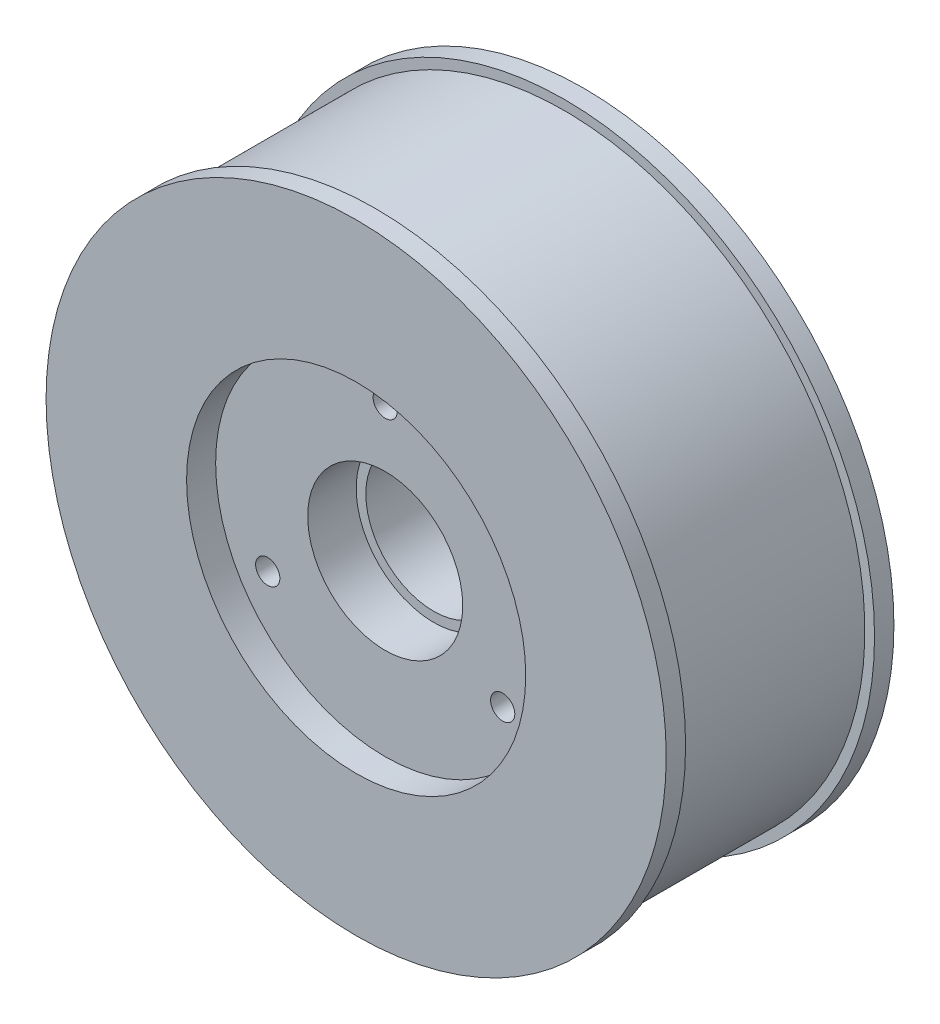
from build123d import *

# Parameters (mm, degrees)
SKETCH1_R             = 31
EXTRUDE1_DEPTH        = 19.5
SKETCH2_R             = 32
EXTRUDE2_DEPTH        = 2
SKETCH3_R             = 32
EXTRUDE3_DEPTH        = 2
SKETCH4_R             = 7
CUT_EXTRUDE1_DEPTH    = 24.5
SKETCH5_R             = 8
CUT_EXTRUDE2_DEPTH    = 9.5
SKETCH6_R             = 18
CUT_EXTRUDE3_DEPTH    = 5
M3X0_5_TAPPED_HOLE1_D = 2.5
SKETCH8_R             = 8
CUT_EXTRUDE4_DEPTH    = 8
SKETCH9_R             = 17.5
CUT_EXTRUDE5_DEPTH    = 3


with BuildPart() as part:
    # Sketch1 → Extrude1 (new body)
    with BuildSketch(Plane.XY):
        Circle(SKETCH1_R)
    extrude(amount=EXTRUDE1_DEPTH)

    # Sketch2 → Extrude2 (add)
    with BuildSketch(Plane.XY.offset(19.5)):
        Circle(SKETCH2_R)
    extrude(amount=EXTRUDE2_DEPTH)

    # Sketch3 → Extrude3 (add)
    with BuildSketch(Plane(origin=(0, 0, 0), x_dir=(-1, 0, 0), z_dir=(0, 0, -1))):
        with Locations(Location((0, 0, 0), (0, 0, 180))):  # turned: the seam where the file's is
            Circle(SKETCH3_R)
    extrude(amount=EXTRUDE3_DEPTH)

    # Sketch4 → Cut-Extrude1 (cut, through all)
    with BuildSketch(Plane(origin=(0, 0, -2), x_dir=(-1, 0, 0), z_dir=(0, 0, -1))):
        Circle(SKETCH4_R)
    extrude(amount=-CUT_EXTRUDE1_DEPTH, mode=Mode.SUBTRACT)

    # Sketch5 → Cut-Extrude2 (cut)
    with BuildSketch(Plane(origin=(0, 0, -2), x_dir=(-1, 0, 0), z_dir=(0, 0, -1))):
        Circle(SKETCH5_R)
    extrude(amount=-CUT_EXTRUDE2_DEPTH, mode=Mode.SUBTRACT)

    # Sketch6 → Cut-Extrude3 (cut)
    with BuildSketch(Plane(origin=(0, 0, -2), x_dir=(-1, 0, 0), z_dir=(0, 0, -1))):
        Circle(SKETCH6_R)
    extrude(amount=-CUT_EXTRUDE3_DEPTH, mode=Mode.SUBTRACT)

    # M3x0.5 Tapped Hole1 (through all)
    with Locations(Plane(origin=(0, 14, 3), x_dir=(-1, 0, 0), z_dir=(0, 0, -1))):
        with Locations((0, 0), (-12.124355653, -21), (12.124355653, -21)):
            Hole(M3X0_5_TAPPED_HOLE1_D / 2)

    # Sketch8 → Cut-Extrude4 (cut)
    with BuildSketch(Plane.XY.offset(21.5)):
        with Locations(Location((0, 0, 0), (0, 0, 180))):  # turned: the seam where the file's is
            Circle(SKETCH8_R)
    extrude(amount=-CUT_EXTRUDE4_DEPTH, mode=Mode.SUBTRACT)

    # Sketch9 → Cut-Extrude5 (cut)
    with BuildSketch(Plane.XY.offset(21.5)):
        Circle(SKETCH9_R)
    extrude(amount=-CUT_EXTRUDE5_DEPTH, mode=Mode.SUBTRACT)


solid = part.part
